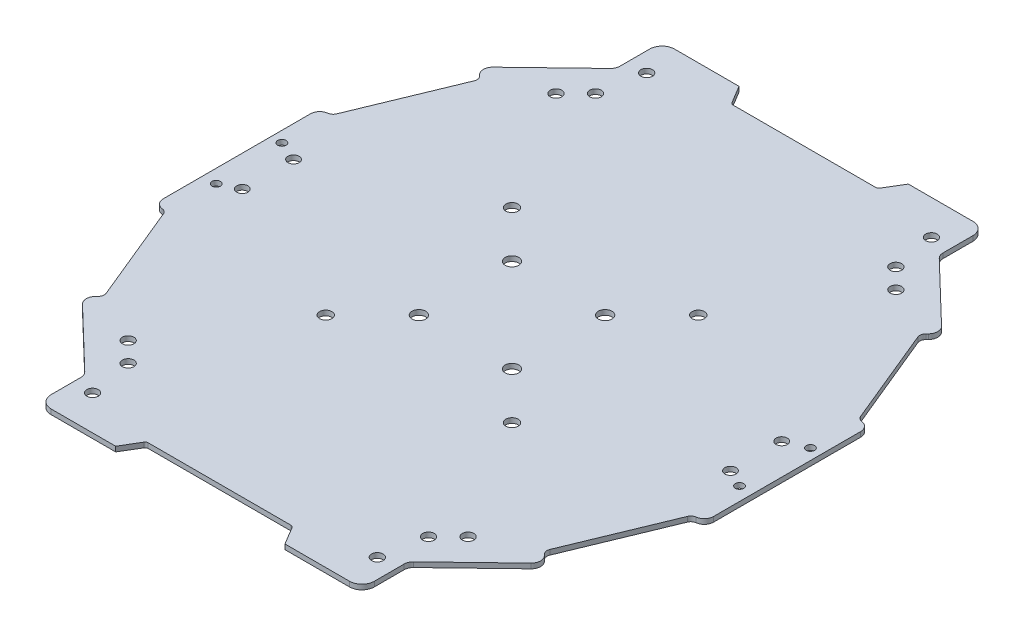
from build123d import *

# Parameters (mm, degrees)
SKETCH1_R        = 2.2
SKETCH1_R_2      = 1.85915493
SKETCH1_R_3      = 1.8
SKETCH1_R_4      = 1.35
SKETCH1_R_5      = 1.983111479
EXTRUSION1_DEPTH = 1.6
FILLET1_R        = 1
FILLET2_R        = 4
FILLET3_R        = 3
FILLET4_R        = 3
FILLET5_R        = 2
FILLET6_R        = 2
FILLET7_R        = 3
FILLET8_R        = 3
FILLET9_R        = 2
FILLET10_R       = 2
FILLET11_R       = 3


with BuildPart() as part:
    # Sketch1 → Extrusion1 (new body)
    with BuildSketch(Plane(origin=(0, 0, 0), x_dir=(-1, 0, 0), z_dir=(0, 1, 0))):
        Polygon((74.087520418, 321.088295015), (70.369210559, 327.285477572), (45.580478165, 327.285477572), (45.580478165, 312.412238135), (23.246043749, 290.934342561), (26.682507041, 287.360833055), (12.735407819, 253.538985229), (9.017097883, 253.538985229), (9.017097883, 226.891111382), (9.017097883, 200.243237534), (12.735407819, 200.243237534), (26.682507041, 166.421389708), (23.246043749, 162.847880202), (45.580478165, 141.369984628), (45.580478165, 126.496745191), (70.369210559, 126.496745191), (74.087520418, 132.693927748), (97.636816193, 132.693927748), (121.186111968, 132.693927748), (124.904421827, 126.496745191), (149.693154221, 126.496745191), (149.693154221, 141.369984628), (172.027588636, 162.847880202), (168.591125345, 166.421389708), (182.538224567, 200.243237534), (186.256534503, 200.243237534), (186.256534503, 226.891111382), (186.256534503, 253.538985229), (182.538224567, 253.538985229), (168.591125345, 287.360833055), (172.027588636, 290.934342561), (149.693154221, 312.412238135), (149.693154221, 327.285477572), (124.904421827, 327.285477572), (121.186111968, 321.088295015), (97.636816193, 321.088295015), align=None)
        with Locations((112.636816193, 211.891111382)):
            Circle(SKETCH1_R, mode=Mode.SUBTRACT)
        with Locations((49.266182018, 151.62213525)):
            Circle(SKETCH1_R_2, mode=Mode.SUBTRACT)
        with Locations((112.636816193, 241.891111382)):
            Circle(SKETCH1_R, mode=Mode.SUBTRACT)
        with Locations((82.636816193, 241.891111382)):
            Circle(SKETCH1_R, mode=Mode.SUBTRACT)
        with Locations((82.636816193, 211.891111382)):
            Circle(SKETCH1_R, mode=Mode.SUBTRACT)
        with Locations((176.256534503, 218.641111382)):
            Circle(SKETCH1_R_3, mode=Mode.SUBTRACT)
        with Locations((176.256534503, 235.141111382)):
            Circle(SKETCH1_R_3, mode=Mode.SUBTRACT)
        with Locations((19.017097883, 218.641111382)):
            Circle(SKETCH1_R_3, mode=Mode.SUBTRACT)
        with Locations((19.017097883, 235.141111382)):
            Circle(SKETCH1_R_3, mode=Mode.SUBTRACT)
        with Locations((182.756534503, 215.891111382)):
            Circle(SKETCH1_R_4, mode=Mode.SUBTRACT)
        with Locations((181.918506411, 237.891111382)):
            Circle(SKETCH1_R_4, mode=Mode.SUBTRACT)
        with Locations((51.777661187, 316.130534525)):
            Circle(SKETCH1_R_2, mode=Mode.SUBTRACT)
        with Locations((49.266182018, 302.160087513)):
            Circle(SKETCH1_R_2, mode=Mode.SUBTRACT)
        with Locations((13.355125975, 237.891111382)):
            Circle(SKETCH1_R_4, mode=Mode.SUBTRACT)
        with Locations((143.495971199, 137.651688238)):
            Circle(SKETCH1_R_2, mode=Mode.SUBTRACT)
        with Locations((146.007450368, 151.62213525)):
            Circle(SKETCH1_R_2, mode=Mode.SUBTRACT)
        with Locations((143.495971199, 316.130534525)):
            Circle(SKETCH1_R_2, mode=Mode.SUBTRACT)
        with Locations((146.007450368, 302.160087513)):
            Circle(SKETCH1_R_2, mode=Mode.SUBTRACT)
        with Locations((12.517097883, 215.891111382)):
            Circle(SKETCH1_R_4, mode=Mode.SUBTRACT)
        with Locations((51.777661187, 137.651688238)):
            Circle(SKETCH1_R_2, mode=Mode.SUBTRACT)
        with Locations((67.636816193, 196.891111382)):
            Circle(SKETCH1_R_5, mode=Mode.SUBTRACT)
        with Locations((67.636816193, 256.891111382)):
            Circle(SKETCH1_R_5, mode=Mode.SUBTRACT)
        with Locations((42.888078851, 158.000238416)):
            Circle(SKETCH1_R_2, mode=Mode.SUBTRACT)
        with Locations((152.385553534, 295.781984347)):
            Circle(SKETCH1_R_2, mode=Mode.SUBTRACT)
        with Locations((42.888078851, 295.781984347)):
            Circle(SKETCH1_R_2, mode=Mode.SUBTRACT)
        with Locations((127.636816193, 256.891111382)):
            Circle(SKETCH1_R_5, mode=Mode.SUBTRACT)
        with Locations((152.385553534, 158.000238416)):
            Circle(SKETCH1_R_2, mode=Mode.SUBTRACT)
        with Locations((127.636816193, 196.891111382)):
            Circle(SKETCH1_R_5, mode=Mode.SUBTRACT)
    extrude(amount=EXTRUSION1_DEPTH)

    # Fillet1
    fillet1_edges = [part.edges().sort_by_distance(p)[0] for p in [
        (-121.186111968, 0.8, 321.088295015),
        (-121.186111968, 0.8, 132.693927748),
        (-74.087520418, 0.8, 132.693927748),
        (-74.087520418, 0.8, 321.088295015),
    ]]
    fillet(fillet1_edges, radius=FILLET1_R)

    # Fillet2
    fillet2_edges = [part.edges().sort_by_distance(p)[0] for p in [
        (-149.693154221, 0.8, 327.285477572),
        (-149.693154221, 0.8, 126.496745191),
        (-45.580478165, 0.8, 126.496745191),
        (-45.580478165, 0.8, 327.285477572),
    ]]
    fillet(fillet2_edges, radius=FILLET2_R)

    # Fillet3
    fillet3_edges = [part.edges().sort_by_distance(p)[0] for p in [
        (-149.693154221, 0.8, 312.412238135),
        (-149.693154221, 0.8, 141.369984628),
        (-45.580478165, 0.8, 141.369984628),
        (-45.580478165, 0.8, 312.412238135),
    ]]
    fillet(fillet3_edges, radius=FILLET3_R)

    # Fillet4
    fillet4_edges = [part.edges().sort_by_distance(p)[0] for p in [
        (-172.027588636, 0.8, 290.934342561),
    ]]
    fillet(fillet4_edges, radius=FILLET4_R)

    # Fillet5
    fillet5_edges = [part.edges().sort_by_distance(p)[0] for p in [
        (-168.591125345, 0.8, 287.360833055),
    ]]
    fillet(fillet5_edges, radius=FILLET5_R)

    # Fillet6
    fillet6_edges = [part.edges().sort_by_distance(p)[0] for p in [
        (-26.682507041, 0.8, 287.360833055),
    ]]
    fillet(fillet6_edges, radius=FILLET6_R)

    # Fillet7
    fillet7_edges = [part.edges().sort_by_distance(p)[0] for p in [
        (-23.246043749, 0.8, 290.934342561),
    ]]
    fillet(fillet7_edges, radius=FILLET7_R)

    # Fillet8
    fillet8_edges = [part.edges().sort_by_distance(p)[0] for p in [
        (-172.027588636, 0.8, 162.847880202),
        (-23.246043749, 0.8, 162.847880202),
    ]]
    fillet(fillet8_edges, radius=FILLET8_R)

    # Fillet9
    fillet9_edges = [part.edges().sort_by_distance(p)[0] for p in [
        (-168.591125345, 0.8, 166.421389708),
        (-26.682507041, 0.8, 166.421389708),
    ]]
    fillet(fillet9_edges, radius=FILLET9_R)

    # Fillet10
    fillet10_edges = [part.edges().sort_by_distance(p)[0] for p in [
        (-182.538224567, 0.8, 253.538985229),
        (-182.538224567, 0.8, 200.243237534),
        (-12.735407819, 0.8, 200.243237534),
        (-12.735407819, 0.8, 253.538985229),
    ]]
    fillet(fillet10_edges, radius=FILLET10_R)

    # Fillet11
    fillet11_edges = [part.edges().sort_by_distance(p)[0] for p in [
        (-186.256534503, 0.8, 200.243237534),
        (-186.256534503, 0.8, 253.538985229),
        (-9.017097883, 0.8, 253.538985229),
        (-9.017097883, 0.8, 200.243237534),
    ]]
    fillet(fillet11_edges, radius=FILLET11_R)


solid = part.part
